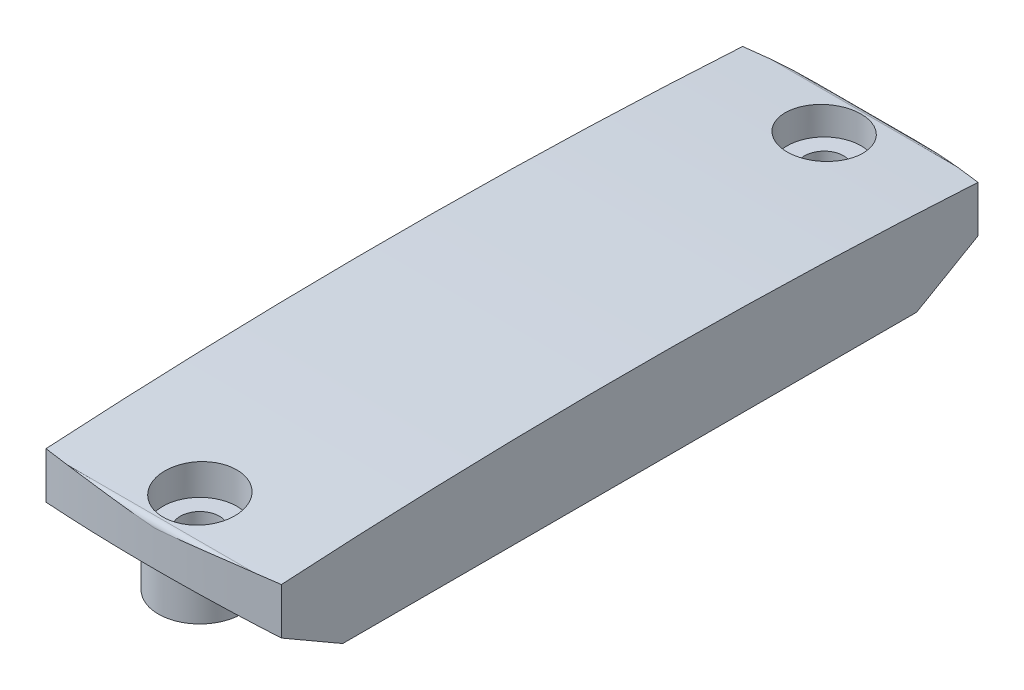
from build123d import *

# Parameters (mm, degrees)
BOSS_EXTRUDE1_DEPTH     = 10
SKETCH2_W               = 83.569070853
SKETCH2_H               = 48.012038302
CUT_EXTRUDE1_DEPTH      = 12
CUT_EXTRUDE1_DEPTH_BACK = 12
BOSS_EXTRUDE2_DEPTH     = 5
BOSS_EXTRUDE3_DEPTH     = 5
SKETCH5_W               = 15.8
SKETCH5_H               = 47
CUT_EXTRUDE2_DEPTH      = 6.5


with BuildPart() as part:
    # Sketch1 → Boss-Extrude1 (new body)
    with BuildSketch(Plane(origin=(0, 0, 0), x_dir=(1, 0, 0), z_dir=(0, 1, 0))):
        with BuildLine():
            Line((10.2, -57.235021417), (10.2, 3.135021417))
            ThreePointArc((10.2, 3.135021417), (0, 3.88), (-10.2, 3.135021417))
            Line((-10.2, 3.135021417), (-10.2, -57.235021417))
            ThreePointArc((-10.2, -57.235021417), (0, -57.98), (10.2, -57.235021417))
        make_face()
    extrude(amount=BOSS_EXTRUDE1_DEPTH)

    # Sketch2 → Cut-Extrude1 (cut, two sides)
    with BuildSketch(Plane(origin=(0, 0, 0), x_dir=(0, 0, -1), z_dir=(1, 0, 0))) as cut_extrude1_sk:
        with Locations((-26.748669216, 4)):
            Rectangle(SKETCH2_W, SKETCH2_H)
        with BuildLine():
            Line((-57.98, 6.572226563), (-57.98, 3.5))
            Line((-57.98, 3.5), (-51.917822174, 0))
            Line((-51.917822174, 0), (-2.182177826, 0))
            Line((-2.182177826, 0), (3.88, 3.5))
            Line((3.88, 3.5), (3.88, 6.572226563))
            ThreePointArc((3.88, 6.572226563), (3.7441635, 6.914841427), (3.410460219, 7.071297876))
            ThreePointArc((3.410460219, 7.071297876), (-27.050000121, 8), (-57.51046046, 7.071297861))
            ThreePointArc((-57.51046046, 7.071297861), (-57.844163583, 6.914841339), (-57.98, 6.572226563))
        make_face(mode=Mode.SUBTRACT)
    extrude(amount=CUT_EXTRUDE1_DEPTH, mode=Mode.SUBTRACT)
    extrude(cut_extrude1_sk.sketch, amount=-CUT_EXTRUDE1_DEPTH_BACK, mode=Mode.SUBTRACT)

    # Sketch3 → Boss-Extrude2 (add)
    with BuildSketch(Plane(origin=(0, 0, 0), x_dir=(1, 0, 0), z_dir=(0, 1, 0))):
        with BuildLine():
            Line((-3.6, 0), (-3.6, -3.6))
            Line((-3.6, -3.6), (3.6, -3.6))
            Line((3.6, -3.6), (3.6, 0))
            ThreePointArc((3.6, 0), (0, 3.600000126), (-3.6, 0))
        make_face()
    extrude(amount=BOSS_EXTRUDE2_DEPTH)

    # Sketch4 → Boss-Extrude3 (add)
    with BuildSketch(Plane(origin=(0, 0, 0), x_dir=(1, 0, 0), z_dir=(0, 1, 0))):
        with BuildLine():
            Line((3.6, -54.1), (3.6, -50.5))
            Line((3.6, -50.5), (-3.6, -50.5))
            Line((-3.6, -50.5), (-3.6, -54.1))
            ThreePointArc((-3.6, -54.1), (0, -57.7), (3.6, -54.1))
        make_face()
    extrude(amount=BOSS_EXTRUDE3_DEPTH)

    # Sketch5 → Cut-Extrude2 (cut)
    with BuildSketch(Plane(origin=(0, 0, 0), x_dir=(1, 0, 0), z_dir=(0, 1, 0))):
        with Locations((0, -27.05)):
            Rectangle(SKETCH5_W, SKETCH5_H)
    extrude(amount=CUT_EXTRUDE2_DEPTH, mode=Mode.SUBTRACT)

    # Sketch6 → Cut-Revolve1 (revolve, cut)
    with BuildSketch(Plane(origin=(0, 0, 0), x_dir=(0, 0, -1), z_dir=(1, 0, 0))):
        Polygon((0, 0), (-1.5, 0), (-1.5, 2.4), (-1.35, 2.4), (-1.35, 3), (-1.7, 3.202072594), (-1.7, 4.7), (-3.2, 4.7), (-3.2, 8), (0, 8), align=None)
    revolve(axis=Axis((0, 8, 0), (0, -1, 0)), mode=Mode.SUBTRACT)

    # Sketch7 → Cut-Revolve2 (revolve, cut)
    with BuildSketch(Plane(origin=(0, 0, 0), x_dir=(0, 0, -1), z_dir=(1, 0, 0))):
        Polygon((-54.1, 0), (-55.6, 0), (-55.6, 2.4), (-55.45, 2.4), (-55.45, 3), (-55.8, 3.202072594), (-55.8, 4.7), (-57.3, 4.7), (-57.3, 8), (-54.1, 8), align=None)
    revolve(axis=Axis((0, 8, 54.1), (0, -1, 0)), mode=Mode.SUBTRACT)


solid = part.part
